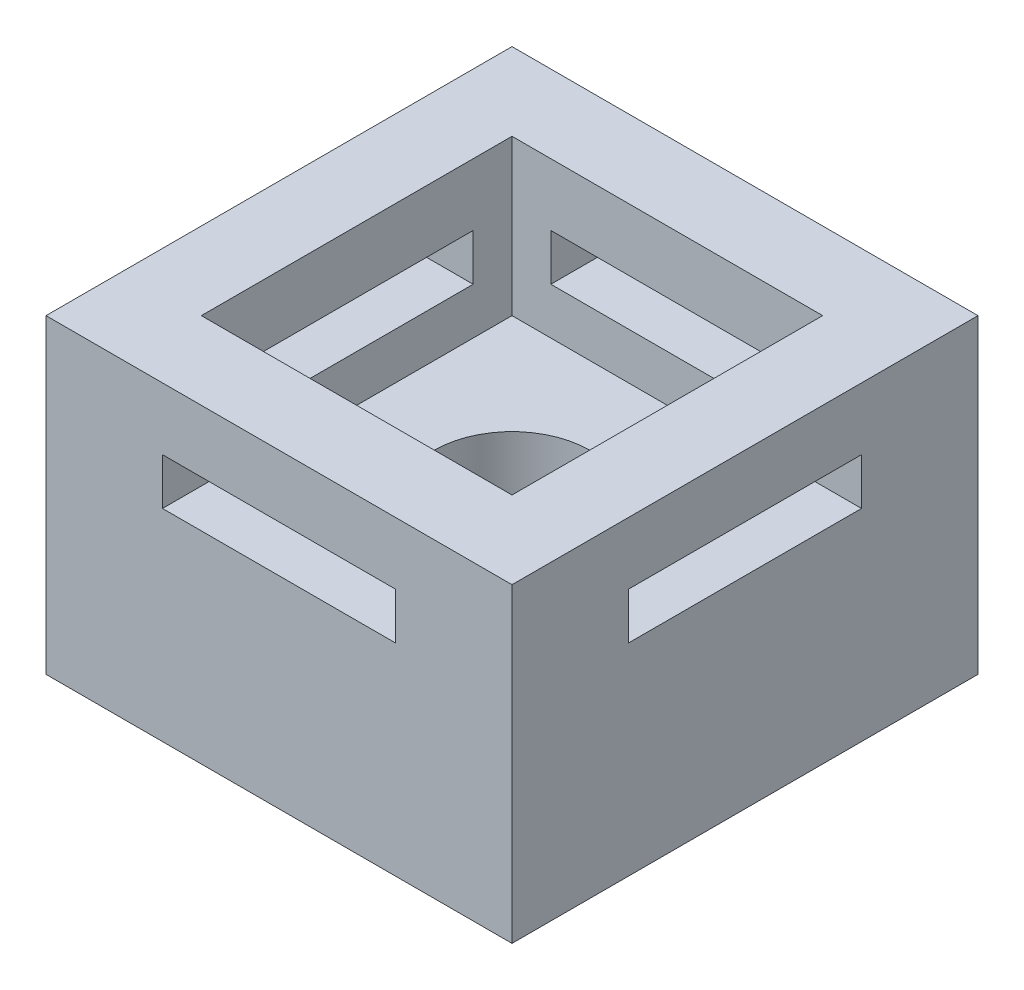
from build123d import *

# Parameters (mm, degrees)
SKETCH1_W           = 15.24
SKETCH1_H           = 15.24
BOSS_EXTRUDE1_DEPTH = 10.16
SKETCH2_R           = 2.54
CUT_EXTRUDE3_DEPTH  = 10.16
SKETCH5_W           = 10.16
SKETCH5_H           = 10.16
CUT_EXTRUDE5_DEPTH  = 5.08
SKETCH7_W           = 7.62
SKETCH7_H           = 1.524
CUT_EXTRUDE6_DEPTH  = 15.24
SKETCH8_W           = 7.62
SKETCH8_H           = 1.524
CUT_EXTRUDE7_DEPTH  = 15.24


with BuildPart() as part:
    # Sketch1 → Boss-Extrude1 (new body)
    with BuildSketch(Plane(origin=(0, 0, 0), x_dir=(1, 0, 0), z_dir=(0, 1, 0))):
        with Locations((7.62, 7.62)):
            Rectangle(SKETCH1_W, SKETCH1_H)
    extrude(amount=BOSS_EXTRUDE1_DEPTH)

    # Sketch2 → Cut-Extrude3 (cut)
    with BuildSketch(Plane(origin=(0, 0, 0), x_dir=(1, 0, 0), z_dir=(0, 1, 0))):
        with Locations((7.62, 7.62)):
            Circle(SKETCH2_R)
    extrude(amount=CUT_EXTRUDE3_DEPTH, mode=Mode.SUBTRACT)

    # Sketch5 → Cut-Extrude5 (cut)
    with BuildSketch(Plane(origin=(0, 10.16, 0), x_dir=(1, 0, 0), z_dir=(0, 1, 0))):
        with Locations((7.62, 7.62)):
            Rectangle(SKETCH5_W, SKETCH5_H)
    extrude(amount=-CUT_EXTRUDE5_DEPTH, mode=Mode.SUBTRACT)

    # Sketch7 → Cut-Extrude6 (cut)
    with BuildSketch(Plane.XY):
        with Locations((7.62, 7.366)):
            Rectangle(SKETCH7_W, SKETCH7_H)
    extrude(amount=-CUT_EXTRUDE6_DEPTH, mode=Mode.SUBTRACT)

    # Sketch8 → Cut-Extrude7 (cut)
    with BuildSketch(Plane(origin=(15.24, 0, 0), x_dir=(0, 0, -1), z_dir=(1, 0, 0))):
        with Locations((7.62, 7.366)):
            Rectangle(SKETCH8_W, SKETCH8_H)
    extrude(amount=-CUT_EXTRUDE7_DEPTH, mode=Mode.SUBTRACT)


solid = part.part
